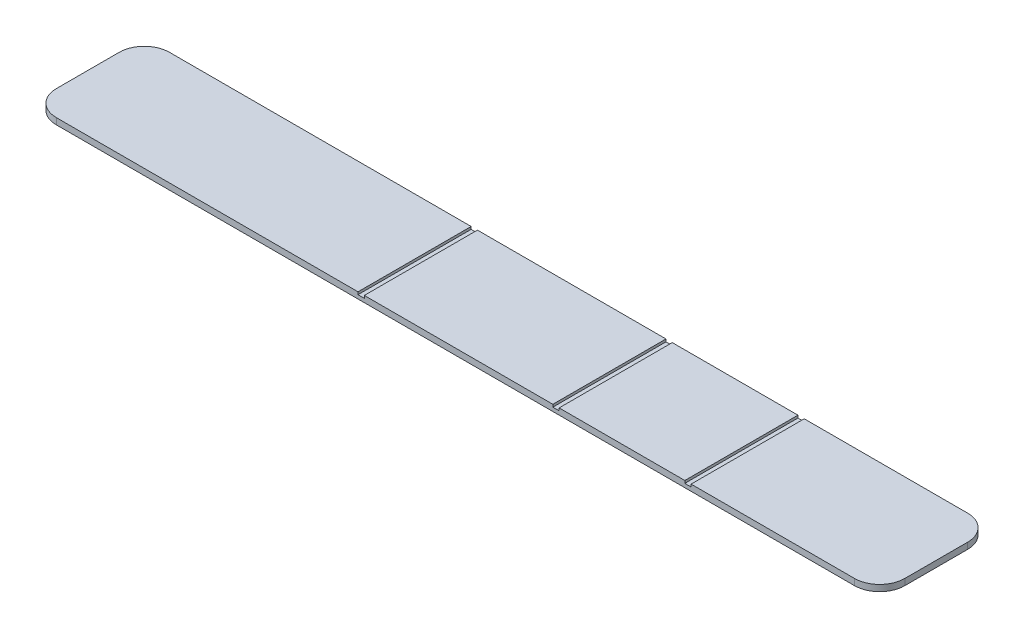
from build123d import *

# Parameters (mm, degrees)
SKETCH1_W           = 135
SKETCH1_H           = 18
BOSS_EXTRUDE1_DEPTH = 1
SKETCH2_W           = 1
SKETCH2_H           = 18
CUT_EXTRUDE1_DEPTH  = 0.4
FILLET1_R           = 4


with BuildPart() as part:
    # Sketch1 → Boss-Extrude1 (new body)
    with BuildSketch(Plane(origin=(0, 0, 0), x_dir=(1, 0, 0), z_dir=(0, 1, 0))):
        with Locations((67.5, 9)):
            Rectangle(SKETCH1_W, SKETCH1_H)
    extrude(amount=BOSS_EXTRUDE1_DEPTH)

    # Sketch2 → Cut-Extrude1 (cut)
    with BuildSketch(Plane(origin=(0, 1, 0), x_dir=(1, 0, 0), z_dir=(0, 1, 0))):
        with Locations((52.5, 9)):
            Rectangle(SKETCH2_W, SKETCH2_H)
        with Locations((83.5, 9)):
            Rectangle(SKETCH2_W, SKETCH2_H)
        with Locations((104.5, 9)):
            Rectangle(SKETCH2_W, SKETCH2_H)
    extrude(amount=-CUT_EXTRUDE1_DEPTH, mode=Mode.SUBTRACT)

    # Fillet1
    fillet1_edges = [part.edges().sort_by_distance(p)[0] for p in [
        (0, 0.5, 0),
        (0, 0.5, -18),
        (135, 0.5, -18),
        (135, 0.5, 0),
    ]]
    fillet(fillet1_edges, radius=FILLET1_R)


solid = part.part
